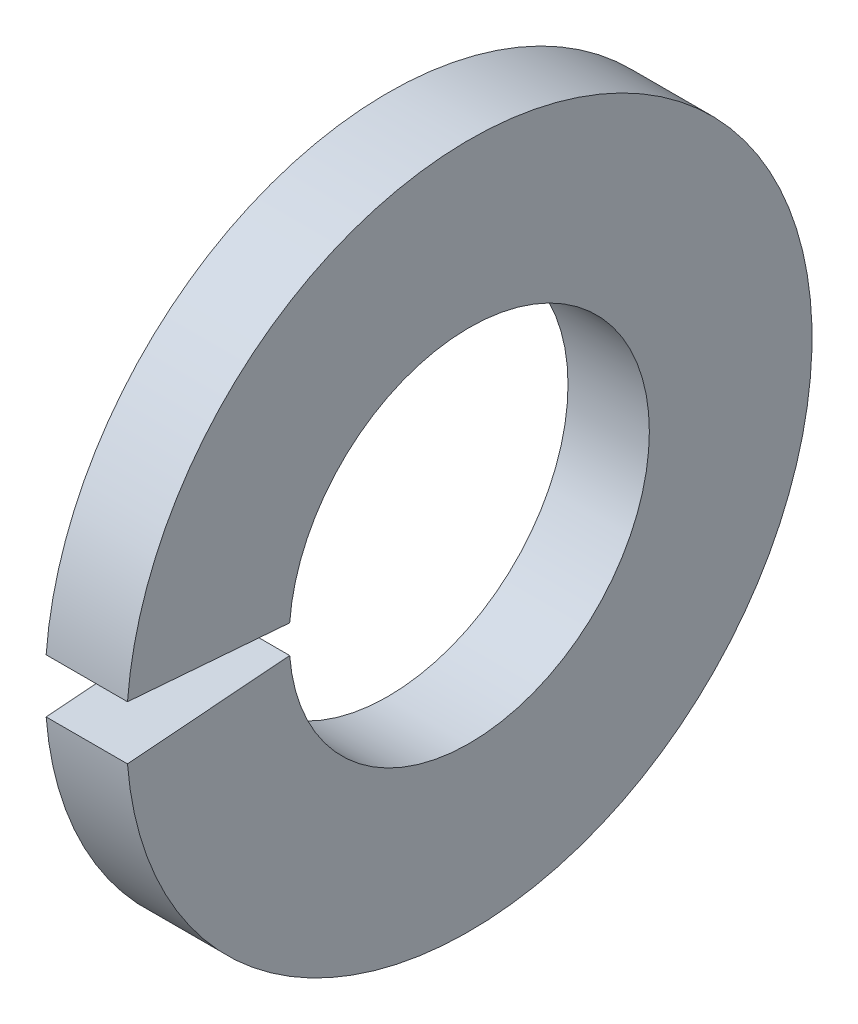
from build123d import *

# Parameters (mm, degrees)
SKETCH1_W = 0.7
SKETCH1_H = 1.4
GAP_DEPTH = 1.7


with BuildPart() as part:
    # Sketch1 → Base-Revolve (revolve)
    with BuildSketch(Plane.XY):
        with Locations((-0.35, 2.25)):
            Rectangle(SKETCH1_W, SKETCH1_H)
    revolve(axis=Axis((-34.925, 0, 0), (1, 0, 0)))

    # Sketch2 → Gap (cut, through all)
    with BuildSketch(Plane(origin=(0, 0, 0), x_dir=(0, -1, 0), z_dir=(-1, 0, 0))):
        with BuildLine():
            Line((0, 0), (0.236083419, 2.999724257))
            ThreePointArc((0.236083419, 2.999724257), (0, 3.009), (-0.236083419, 2.999724257))
            Line((-0.236083419, 2.999724257), (0, 0))
        make_face()
    extrude(amount=GAP_DEPTH, mode=Mode.SUBTRACT)


solid = part.part
